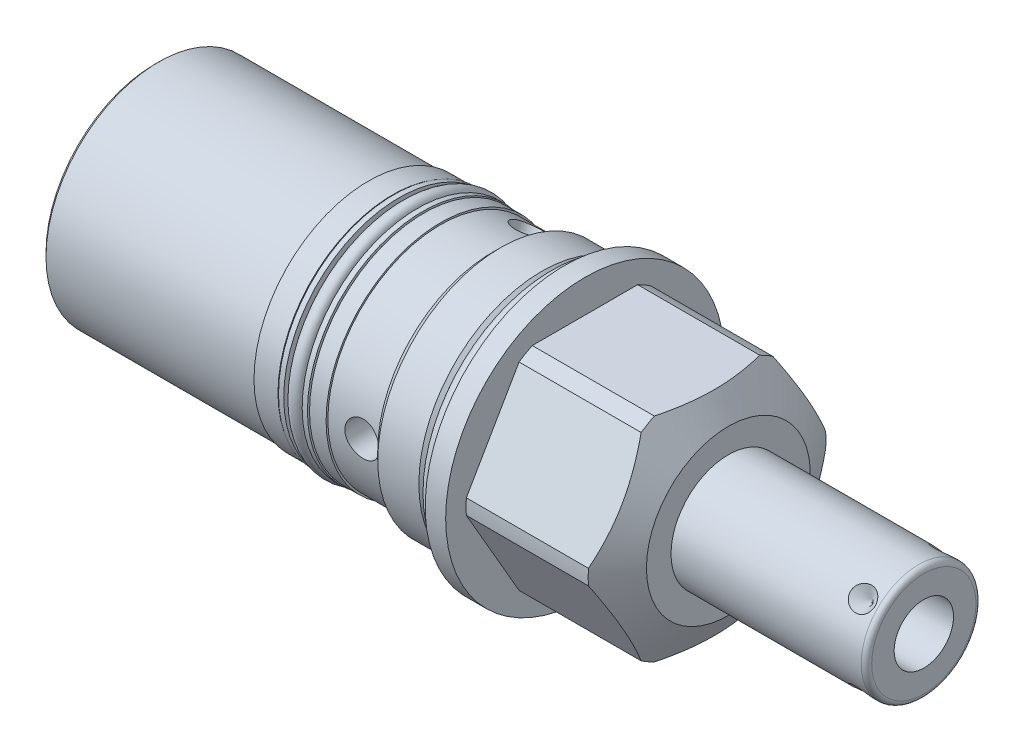
from build123d import *

# Parameters (mm, degrees)
SKETCH1_R           = 26.9875
EXTRUDE1_DEPTH      = 31.75
EXTRUDE1_DEPTH_BACK = 79.375
CUT_EXTRUDE1_REACH  = 81.375
SKETCH2_R           = 26.9875
SKETCH2_R_2         = 23.8125
CUT_EXTRUDE3_REACH  = 31.362
CUT_EXTRUDE3_START  = -0.7874
SKETCH5_R           = 26.9875
CUT_EXTRUDE5_REACH  = 29.788
SKETCH7_R           = 26.9875
SKETCH7_R_2         = 23.0251
SKETCH12_W          = 6.1087
SKETCH12_H          = 2.032
SKETCH14_W          = 0.3429
SKETCH14_H          = 41.402
SKETCH14_H_2        = 10.0076
SKETCH15_R          = 1.4986
SKETCH16_W          = 2.1844
SKETCH16_H          = 1.016
SKETCH17_R          = 1.3081
CHAMFER1_SIZE       = 0.762
SKETCH23_R          = 3.3147
CUT_EXTRUDE7_DEPTH  = 27.9875
SKETCH26_R          = 3.1369
CUT_EXTRUDE8_DEPTH  = 0.762
SKETCH27_R          = 17.7927
EXTRUDE2_DEPTH      = 0.508
SKETCH28_R          = 3.1369
CUT_EXTRUDE9_DEPTH  = 0.508
CIRPATTERN2_COUNT   = 3
CIRPATTERN3_COUNT   = 4


with BuildPart() as part:
    # Sketch1 → Extrude1 (new body, two sides)
    with BuildSketch(Plane(origin=(0, 0, 0), x_dir=(0, 0, -1), z_dir=(1, 0, 0))) as extrude1_sk:
        Circle(SKETCH1_R)
    extrude(amount=EXTRUDE1_DEPTH)
    extrude(extrude1_sk.sketch, amount=-EXTRUDE1_DEPTH_BACK)

    # Sketch2 → Cut-Extrude1 (cut, up to next)
    with BuildSketch(Plane(origin=(0, 0, 0), x_dir=(0, 0, -1), z_dir=(1, 0, 0)), mode=Mode.PRIVATE) as cut_extrude1_sk1:
        Circle(SKETCH2_R)
        Circle(SKETCH2_R_2, mode=Mode.SUBTRACT)
    cut_extrude1_tool1 = extrude(cut_extrude1_sk1.sketch, amount=-CUT_EXTRUDE1_REACH, mode=Mode.PRIVATE) & part.part
    add(cut_extrude1_tool1.solids().sort_by_distance((0, 0, 26.224178))[0], mode=Mode.SUBTRACT)

    # Sketch3 → Cut-Revolve1 (revolve, cut)
    with BuildSketch(Plane.XY, mode=Mode.PRIVATE) as cut_revolve1_sk:
        Polygon((25.334195134, 26.9875), (31.75, 15.875), (31.75, 26.9875), align=None)
    revolve(cut_revolve1_sk.sketch.rotate(Axis((-8.14577342, 0, 0), (1, 0, 0)), 270), axis=Axis((-8.14577342, 0, 0), (1, 0, 0)), mode=Mode.SUBTRACT)  # turned: the seam where the file's is

    # Cut-Extrude3: up to this cone (the profile starts inside it)
    cut_extrude3_end = Plane(origin=(3.9624, 0, 0), z_dir=(-1, 0, 0)).offset(-36.953034523) * Cone(1.732e-06, 230.050244421, 132.819569544, align=(Align.CENTER, Align.CENTER, Align.MIN), mode=Mode.PRIVATE)
    # Sketch5 → Cut-Extrude3 (cut, up to the surface)
    with BuildSketch(Plane.ZY.offset(-3.175).offset(CUT_EXTRUDE3_START), mode=Mode.PRIVATE) as cut_extrude3_sk1:
        with Locations(Location((0, 0, 0), (0, 0, 180))):  # turned: the seam where the file's is
            Circle(SKETCH5_R)
        Polygon((-11.91506618, 20.6375), (11.91506618, 20.6375), (23.830132361, 0), (11.91506618, -20.6375), (-11.91506618, -20.6375), (-23.830132361, 0), align=None, mode=Mode.SUBTRACT)
    cut_extrude3_tool1 = extrude(cut_extrude3_sk1.sketch, amount=-CUT_EXTRUDE3_REACH, mode=Mode.PRIVATE) & cut_extrude3_end
    add(cut_extrude3_tool1.solids().sort_by_distance((3.9624, 0, 26.224178))[0], mode=Mode.SUBTRACT)

    # Cut-Extrude5: up to this cone (the profile starts inside it)
    cut_extrude5_end = Plane(origin=(3.9624, 0, 0), z_dir=(-1, 0, 0)).offset(-36.953034523) * Cone(1.732e-06, 227.32399645, 131.245569544, align=(Align.CENTER, Align.CENTER, Align.MIN), mode=Mode.PRIVATE)
    # Sketch7 → Cut-Extrude5 (cut, up to the surface)
    with BuildSketch(Plane.ZY.offset(-3.9624), mode=Mode.PRIVATE) as cut_extrude5_sk1:
        with Locations(Location((0, 0, 0), (0, 0, 180))):  # turned: the seam where the file's is
            Circle(SKETCH7_R)
        Circle(SKETCH7_R_2, mode=Mode.SUBTRACT)
    cut_extrude5_tool1 = extrude(cut_extrude5_sk1.sketch, amount=-CUT_EXTRUDE5_REACH, mode=Mode.PRIVATE) & cut_extrude5_end
    add(cut_extrude5_tool1.solids().sort_by_distance((3.9624, 0, 26.224178))[0], mode=Mode.SUBTRACT)

    # Sketch9 → Cut-Revolve3 (revolve, cut)
    with BuildSketch(Plane.XY, mode=Mode.PRIVATE) as cut_revolve3_sk:
        Polygon((0, 23.8125), (0, 22.3012), (-2.8956, 22.3012), (-4.4069, 23.8125), align=None)
    revolve(cut_revolve3_sk.sketch.rotate(Axis((-4.4205525, 0, 0), (1, 0, 0)), 90), axis=Axis((-4.4205525, 0, 0), (1, 0, 0)), mode=Mode.SUBTRACT)  # turned: the seam where the file's is

    # Sketch10 → Cut-Revolve4 (revolve, cut)
    with BuildSketch(Plane.XY, mode=Mode.PRIVATE) as cut_revolve4_sk:
        Polygon((-12.3698, 23.8125), (-13.9954, 22.1869), (-79.375, 22.1869), (-79.375, 23.8125), align=None)
    revolve(cut_revolve4_sk.sketch.rotate(Axis((-55.9469925, 0, 0), (1, 0, 0)), 90), axis=Axis((-55.9469925, 0, 0), (1, 0, 0)), mode=Mode.SUBTRACT)  # turned: the seam where the file's is

    # Sketch12 → Cut-Revolve6 (revolve, cut)
    with BuildSketch(Plane.XY, mode=Mode.PRIVATE) as cut_revolve6_sk:
        with Locations((-30.27045, 21.1709)):
            Rectangle(SKETCH12_W, SKETCH12_H)
    revolve(cut_revolve6_sk.sketch.rotate(Axis((-31.750635, 0, 0), (1, 0, 0)), 90), axis=Axis((-31.750635, 0, 0), (1, 0, 0)), mode=Mode.SUBTRACT)  # turned: the seam where the file's is

    # Sketch14 → Cut-Revolve8 (revolve, cut)
    with BuildSketch(Plane(origin=(0, 0, 0), x_dir=(0, -1, 0), z_dir=(0, 0, 1)), mode=Mode.PRIVATE) as cut_revolve8_sk:
        with Locations((22.01545, -58.674)):
            Rectangle(SKETCH14_W, SKETCH14_H)
        with Locations((22.01545, -18.9992)):
            Rectangle(SKETCH14_W, SKETCH14_H_2)
    revolve(cut_revolve8_sk.sketch.rotate(Axis((-55.86603, 0, 0), (1, 0, 0)), 270), axis=Axis((-55.86603, 0, 0), (1, 0, 0)), mode=Mode.SUBTRACT)  # turned: the seam where the file's is

    # Sketch16 → Revolve2 (revolve)
    with BuildSketch(Plane(origin=(0, 0, 0), x_dir=(0, -1, 0), z_dir=(0, 0, 1)), mode=Mode.PRIVATE) as revolve2_sk:
        with Locations((21.2471, -27.9781)):
            Rectangle(SKETCH16_W, SKETCH16_H)
        with Locations((21.2471, -32.5628)):
            Rectangle(SKETCH16_W, SKETCH16_H)
    revolve(revolve2_sk.sketch.rotate(Axis((-31.471235, 0, 0), (1, 0, 0)), 270), axis=Axis((-31.471235, 0, 0), (1, 0, 0)))  # turned: the seam where the file's is

    # S2D0001 → Revolve4 (revolve)
    with BuildSketch(Plane(origin=(0, 0, 0), x_dir=(0, -1, 0), z_dir=(0, 0, 1)), mode=Mode.PRIVATE) as revolve4_sk:
        with BuildLine():
            Line((0, 31.75), (-11.1125, 31.75))
            Line((-11.1125, 31.75), (-11.1125, 68.6054))
            ThreePointArc((-11.1125, 68.6054), (-10.81492049, 69.32382049), (-10.0965, 69.6214))
            Line((-10.0965, 69.6214), (0, 69.6214))
            Line((0, 69.6214), (0, 31.75))
        make_face()
    revolve(revolve4_sk.sketch.rotate(Axis((7.265766347, 0, 0), (1, 0, 0)), 90), axis=Axis((7.265766347, 0, 0), (1, 0, 0)))  # turned: the seam where the file's is

    # Sketch19 → Cut-Revolve9 (revolve, cut)
    with BuildSketch(Plane(origin=(36.322, -2.8067, 0), x_dir=(0, -1, 0), z_dir=(0, 0, 1)), mode=Mode.PRIVATE) as cut_revolve9_sk:
        Polygon((2.9464, 33.2994), (2.9464, 16.2814), (-2.8067, 12.824588773), (-2.8067, 33.2994), align=None)
    revolve(cut_revolve9_sk.sketch.rotate(Axis((17.699325537, 0, 0), (1, 0, 0)), 270), axis=Axis((17.699325537, 0, 0), (1, 0, 0)), mode=Mode.SUBTRACT)  # turned: the seam where the file's is

    # S2D0002 → Cut-Revolve10 (revolve, cut)
    with BuildSketch(Plane(origin=(32.3596, -3.928862053, -3.928862053), x_dir=(1, 0, 0), z_dir=(0, 0.707106781, -0.707106781)), mode=Mode.PRIVATE) as cut_revolve10_sk:
        Polygon((33.2994, 5.55625), (35.7124, 5.55625), (33.2994, 3.14325), align=None)
    cut_revolve10 = revolve(cut_revolve10_sk.sketch.rotate(Axis((65.659, -1.549290214, -1.549290214), (0, -0.707106781, -0.707106781)), 270), axis=Axis((65.659, -1.549290214, -1.549290214), (0, -0.707106781, -0.707106781)), mode=Mode.SUBTRACT)  # turned: the seam where the file's is

    # Chamfer1
    chamfer1_edges = [part.edges().sort_by_distance(p)[0] for p in [
        (-79.375, 0, -21.844),
    ]]
    chamfer(chamfer1_edges, length=CHAMFER1_SIZE)

    # Sketch23 → Cut-Extrude7 (cut, through all)
    with BuildSketch(Plane.XY):
        with Locations((-17.399, 0)):
            Circle(SKETCH23_R)
    cut_extrude7 = extrude(amount=CUT_EXTRUDE7_DEPTH, mode=Mode.SUBTRACT)

    # Sketch26 → Cut-Extrude8 (cut)
    with BuildSketch(Plane.ZY.offset(79.375)):
        Circle(SKETCH26_R)
    extrude(amount=-CUT_EXTRUDE8_DEPTH, mode=Mode.SUBTRACT)

    # Sketch27 → Extrude2 (add)
    with BuildSketch(Plane.ZY.offset(79.375)):
        with Locations(Location((0, 0, 0), (0, 0, 180))):  # turned: the seam where the file's is
            Circle(SKETCH27_R)
    extrude(amount=EXTRUDE2_DEPTH)

    # Sketch28 → Cut-Extrude9 (cut)
    with BuildSketch(Plane.ZY.offset(79.883)):
        Circle(SKETCH28_R)
    extrude(amount=-CUT_EXTRUDE9_DEPTH, mode=Mode.SUBTRACT)

    # CirPattern2: Cut-Extrude7 ×3 about axis
    cirpattern2_axis = Axis((7.265766347, 0, 0), (-1, 0, 0))
    for i in range(1, CIRPATTERN2_COUNT):
        add(cut_extrude7.rotate(cirpattern2_axis, i * 360 / CIRPATTERN2_COUNT), mode=Mode.SUBTRACT)

    # CirPattern3: Cut-Revolve10 ×4 about axis
    cirpattern3_axis = Axis((7.265766347, 0, 0), (-1, 0, 0))
    for i in range(1, CIRPATTERN3_COUNT):
        add(cut_revolve10.rotate(cirpattern3_axis, i * 360 / CIRPATTERN3_COUNT), mode=Mode.SUBTRACT)


with BuildPart() as body_2:
    # Sketch15 → Revolve1 (revolve)
    with BuildSketch(Plane(origin=(0, 0, 0), x_dir=(0, -1, 0), z_dir=(0, 0, 1)), mode=Mode.PRIVATE) as revolve1_sk:
        with Locations((23.7998, -1.4986)):
            Circle(SKETCH15_R)
    revolve(revolve1_sk.sketch.rotate(Axis((-3.09372, 0, 0), (1, 0, 0)), 270), axis=Axis((-3.09372, 0, 0), (1, 0, 0)))  # turned: the seam where the file's is


with BuildPart() as body_3:
    # Sketch17 → Revolve3 (revolve)
    with BuildSketch(Plane(origin=(0, 0, 0), x_dir=(0, -1, 0), z_dir=(0, 0, 1)), mode=Mode.PRIVATE) as revolve3_sk:
        with Locations((21.463, -30.27045)):
            Circle(SKETCH17_R)
    revolve(revolve3_sk.sketch.rotate(Axis((-31.750635, 0, 0), (1, 0, 0)), 270), axis=Axis((-31.750635, 0, 0), (1, 0, 0)))  # turned: the seam where the file's is


solid = Compound([part.part, body_2.part, body_3.part])
